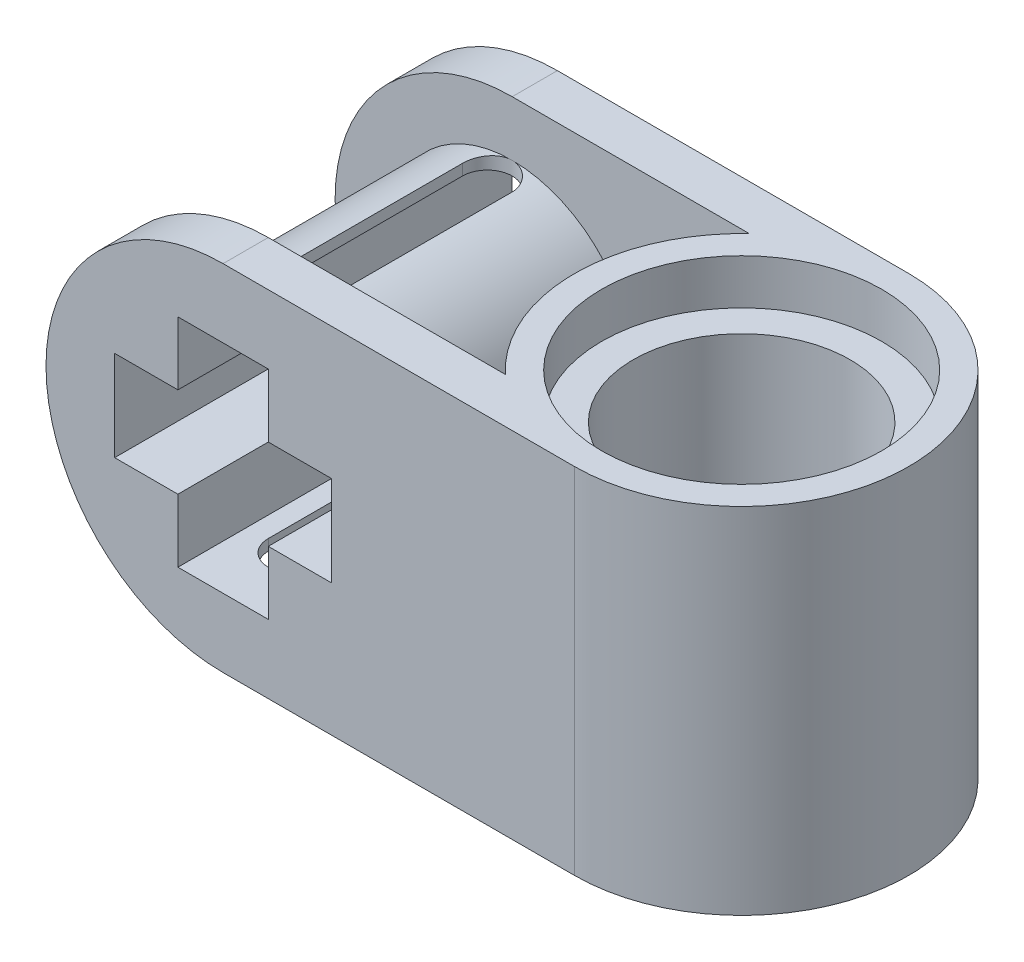
from build123d import *

# Parameters (mm, degrees)
SKETCH1_R           = 3.7
SKETCH1_R_2         = 3.1
SKETCH1_R_3         = 2.4
BOSS_EXTRUDE2_DEPTH = 7.84
SKETCH1_5_R         = 3.1
SKETCH1_5_R_2       = 2.4
CUT_EXTRUDE1_DEPTH  = 1
SKETCH3_R           = 3.1
SKETCH3_R_2         = 2.4
CUT_EXTRUDE2_DEPTH  = 1
BOSS_EXTRUDE3_DEPTH = 7.84
CUT_EXTRUDE3_REACH  = 17.91
CUT_EXTRUDE4_DEPTH  = 16.90960716
SKETCH4_5_R         = 2.7
BOSS_EXTRUDE4_DEPTH = 7.4
CUT_EXTRUDE5_DEPTH  = 15.561785605


with BuildPart() as part:
    # Sketch1 → Boss-Extrude2 (new body)
    with BuildSketch(Plane(origin=(0, 0, 0), x_dir=(1, 0, 0), z_dir=(0, 1, 0))):
        with Locations(Location((0, 0, 0), (0, 0, 270))):
            Circle(SKETCH1_R)
        Circle(SKETCH1_R_2, mode=Mode.SUBTRACT)
        Circle(SKETCH1_R_2)
        with Locations(Location((0, 0, 0), (0, 0, 270))):
            Circle(SKETCH1_R_3, mode=Mode.SUBTRACT)
    extrude(amount=BOSS_EXTRUDE2_DEPTH)

    # Sketch1_5 → Cut-Extrude1 (cut)
    with BuildSketch(Plane(origin=(0, 0, 0), x_dir=(1, 0, 0), z_dir=(0, 1, 0))):
        with Locations(Location((0, 0, 0), (0, 0, 270))):
            Circle(SKETCH1_5_R)
        with Locations(Location((0, 0, 0), (0, 0, 270))):
            Circle(SKETCH1_5_R_2, mode=Mode.SUBTRACT)
    extrude(amount=CUT_EXTRUDE1_DEPTH, mode=Mode.SUBTRACT)

    # Sketch3 → Cut-Extrude2 (cut)
    with BuildSketch(Plane(origin=(0, 7.84, 0), x_dir=(1, 0, 0), z_dir=(0, 1, 0))):
        with Locations(Location((0, 0, 0), (0, 0, 270))):
            Circle(SKETCH3_R)
        with Locations(Location((0, 0, 0), (0, 0, 270))):
            Circle(SKETCH3_R_2, mode=Mode.SUBTRACT)
    extrude(amount=-CUT_EXTRUDE2_DEPTH, mode=Mode.SUBTRACT)

    # Sketch1_6 → Boss-Extrude3 (add)
    with BuildSketch(Plane(origin=(0, 0, 0), x_dir=(1, 0, 0), z_dir=(0, 1, 0))):
        with BuildLine():
            Line((-11.7, -2.7), (-11.7, -3.7))
            Line((-11.7, -3.7), (0, -3.7))
            ThreePointArc((0, -3.7), (-1.360147051, -3.440930107), (-2.529822128, -2.7))
            Line((-2.529822128, -2.7), (-11.7, -2.7))
        make_face()
        with BuildLine():
            Line((-11.7, 3.7), (-11.7, 2.7))
            Line((-11.7, 2.7), (-2.529822128, 2.7))
            ThreePointArc((-2.529822128, 2.7), (-1.360147051, 3.440930107), (0, 3.7))
            Line((0, 3.7), (-11.7, 3.7))
        make_face()
    extrude(amount=BOSS_EXTRUDE3_DEPTH)

    # Cut-Extrude3: up to this face of the body (flat: up to its plane)
    cut_extrude3_end = Plane(part.part.faces().sort_by_distance((-5.85, 3.92, 3.7))[0])
    # Sketch4 → Cut-Extrude3 (cut, up to the picked face)
    with BuildSketch(Plane(origin=(0, 0, -3.7), x_dir=(-1, 0, 0), z_dir=(0, 0, -1)), mode=Mode.PRIVATE) as cut_extrude3_sk1:
        with BuildLine():
            Line((11.7, 7.84), (7.78, 7.84))
            ThreePointArc((7.78, 7.84), (10.551858582, 6.691858582), (11.7, 3.92))
            Line((11.7, 3.92), (11.7, 7.84))
        make_face()
    cut_extrude3_tool1 = split(extrude(cut_extrude3_sk1.sketch, amount=-CUT_EXTRUDE3_REACH, mode=Mode.PRIVATE), bisect_by=cut_extrude3_end, keep=Keep.BOTH, mode=Mode.PRIVATE)
    # Sketch4 → Cut-Extrude3 (cut, up to the picked face)
    with BuildSketch(Plane(origin=(0, 0, -3.7), x_dir=(-1, 0, 0), z_dir=(0, 0, -1)), mode=Mode.PRIVATE) as cut_extrude3_sk2:
        with BuildLine():
            Line((11.7, 0), (11.7, 3.92))
            ThreePointArc((11.7, 3.92), (10.551858582, 1.148141418), (7.78, 0))
            Line((7.78, 0), (11.7, 0))
        make_face()
    cut_extrude3_tool2 = split(extrude(cut_extrude3_sk2.sketch, amount=-CUT_EXTRUDE3_REACH, mode=Mode.PRIVATE), bisect_by=cut_extrude3_end, keep=Keep.BOTH, mode=Mode.PRIVATE)
    add(cut_extrude3_tool1.solids().sort_by(Axis((-10.824398, 6.964398, -3.7), (0, 0, 1)))[0], mode=Mode.SUBTRACT)
    add(cut_extrude3_tool2.solids().sort_by(Axis((-10.824398, 0.875602, -3.7), (0, 0, 1)))[0], mode=Mode.SUBTRACT)

    # Sketch4_4 → Cut-Extrude4 (cut, through all)
    with BuildSketch(Plane(origin=(0, 0, -3.7), x_dir=(-1, 0, 0), z_dir=(0, 0, -1))):
        Polygon((8.78, 4.92), (8.78, 6.32), (6.78, 6.32), (6.78, 4.92), (5.38, 4.92), (5.38, 2.92), (6.78, 2.92), (6.78, 1.52), (8.78, 1.52), (8.78, 2.92), (10.18, 2.92), (10.18, 4.92), align=None)
    extrude(amount=-CUT_EXTRUDE4_DEPTH, mode=Mode.SUBTRACT)

    # Sketch4_5 → Boss-Extrude4 (add, through all)
    with BuildSketch(Plane(origin=(0, 0, -3.7), x_dir=(-1, 0, 0), z_dir=(0, 0, -1))):
        with Locations((7.78, 3.92)):
            Circle(SKETCH4_5_R)
        Polygon((8.78, 6.32), (8.78, 4.92), (10.18, 4.92), (10.18, 2.92), (8.78, 2.92), (8.78, 1.52), (6.78, 1.52), (6.78, 2.92), (5.38, 2.92), (5.38, 4.92), (6.78, 4.92), (6.78, 6.32), align=None, mode=Mode.SUBTRACT)
    extrude(amount=-BOSS_EXTRUDE4_DEPTH)

    # Sketch5 → Cut-Extrude5 (cut, through all)
    with BuildSketch(Plane(origin=(0, 0, 0), x_dir=(1, 0, 0), z_dir=(0, 1, 0))):
        with BuildLine():
            Line((-8.33, -2.15), (-8.33, 2.15))
            ThreePointArc((-8.33, 2.15), (-7.78, 2.7), (-7.23, 2.15))
            Line((-7.23, 2.15), (-7.23, -2.15))
            ThreePointArc((-7.23, -2.15), (-7.78, -2.7), (-8.33, -2.15))
        make_face()
    extrude(amount=CUT_EXTRUDE5_DEPTH, mode=Mode.SUBTRACT)


solid = part.part
